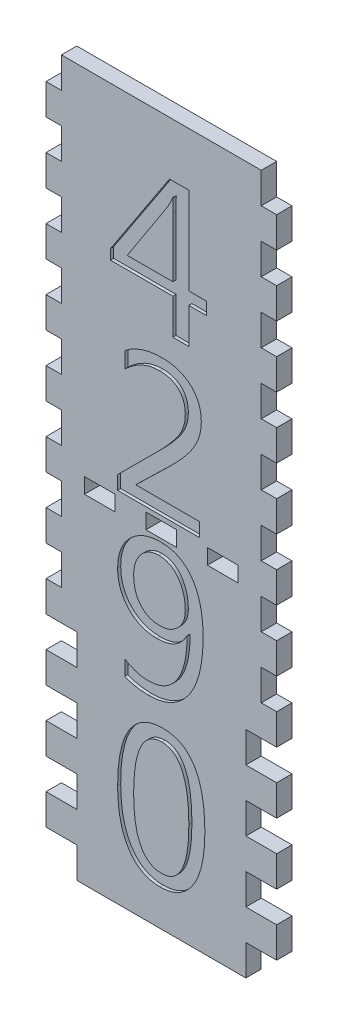
from build123d import *

# Parameters (mm, degrees)
SKETCH1_W           = 95.25
SKETCH1_H           = 292.1
BOSS_EXTRUDE1_DEPTH = 6.35
SKETCH2_W           = 6.35
SKETCH2_H           = 12.7
CUT_EXTRUDE1_DEPTH  = 7.35
LPATTERN1_COUNT     = 12
LPATTERN1_PITCH     = 25.4
SKETCH3_W           = 6.35
SKETCH3_H           = 12.7
CUT_EXTRUDE2_DEPTH  = 7.35
LPATTERN2_COUNT     = 4
LPATTERN2_PITCH     = 25.4
SKETCH4_W           = 12.7
SKETCH4_H           = 6.35
CUT_EXTRUDE3_DEPTH  = 7.35
LPATTERN3_COUNT     = 2
LPATTERN3_PITCH     = 25.4
LPATTERN3_COL_COUNT = 2
LPATTERN3_COL_PITCH = 25.4
CUT_EXTRUDE4_DEPTH  = 1.27


with BuildPart() as part:
    # Sketch1 → Boss-Extrude1 (new body)
    with BuildSketch(Plane.XY):
        with Locations((47.625, 146.05)):
            Rectangle(SKETCH1_W, SKETCH1_H)
    extrude(amount=BOSS_EXTRUDE1_DEPTH)

    # Sketch2 → Cut-Extrude1 (cut, through all)
    with BuildSketch(Plane.XY.offset(6.35)):
        with Locations((3.175, 6.35)):
            Rectangle(SKETCH2_W, SKETCH2_H)
        with Locations((92.075, 6.35)):
            Rectangle(SKETCH2_W, SKETCH2_H)
    cut_extrude1 = extrude(amount=-CUT_EXTRUDE1_DEPTH, mode=Mode.SUBTRACT)

    # LPattern1: Cut-Extrude1 ×12
    with Locations(*[(0, i * LPATTERN1_PITCH, 0) for i in range(1, LPATTERN1_COUNT)]):
        add(cut_extrude1, mode=Mode.SUBTRACT)

    # Sketch3 → Cut-Extrude2 (cut, through all)
    with BuildSketch(Plane.XY.offset(6.35)):
        with Locations((85.725, 6.35)):
            Rectangle(SKETCH3_W, SKETCH3_H)
        with Locations((9.525, 6.35)):
            Rectangle(SKETCH3_W, SKETCH3_H)
    cut_extrude2 = extrude(amount=-CUT_EXTRUDE2_DEPTH, mode=Mode.SUBTRACT)

    # LPattern2: Cut-Extrude2 ×4
    with Locations(*[(0, i * LPATTERN2_PITCH, 0) for i in range(1, LPATTERN2_COUNT)]):
        add(cut_extrude2, mode=Mode.SUBTRACT)

    # Sketch4 → Cut-Extrude3 (cut, through all)
    with BuildSketch(Plane.XY.offset(6.35)):
        with Locations((47.625, 142.875)):
            Rectangle(SKETCH4_W, SKETCH4_H)
    cut_extrude3 = extrude(amount=-CUT_EXTRUDE3_DEPTH, mode=Mode.SUBTRACT)

    # LPattern3: Cut-Extrude3 ×2
    with Locations(*[(-i * LPATTERN3_PITCH, 0, 0) for i in range(1, LPATTERN3_COUNT)]):
        add(cut_extrude3, mode=Mode.SUBTRACT)

    # LPattern3 col: Cut-Extrude3 ×2
    with Locations(*[(i * LPATTERN3_COL_PITCH, 0, 0) for i in range(1, LPATTERN3_COL_COUNT)]):
        add(cut_extrude3, mode=Mode.SUBTRACT)

    # Sketch5 → Cut-Extrude4 (cut)
    with BuildSketch(Plane.XY.offset(6.35)):
        Polygon((66.347473684, 228.827263158), (58.994842105, 228.827263158), (58.994842105, 214.122), (52.377473684, 214.122), (52.377473684, 228.827263158), (26.643263158, 228.827263158), (26.643263158, 232.963118421), (50.987366776, 270.002), (58.994842105, 270.002), (58.994842105, 233.974105263), (66.347473684, 233.974105263), align=None)
        with BuildLine():
            Line((52.377473684, 233.974105263), (52.377473684, 258.306720395))
            add(Edge.make_bspline(
                [(52.377473684, 258.306720395), (52.388280309, 259.222092385), (52.411121203, 261.156823508), (52.494422978, 263.089912378), (52.5383125, 264.10840625)],
                knots=[0, 0, 0, 0, 0.002746133, 0.005804229, 0.005804229, 0.005804229, 0.005804229], degree=3))
            Line((52.5383125, 264.10840625), (52.377473684, 264.10840625))
            add(Edge.make_bspline(
                [(52.377473684, 264.10840625), (52.268298001, 263.83954225), (52.024369803, 263.238826877), (51.566852144, 262.248813106), (50.970030559, 261.082008962), (50.525074381, 260.240044684), (50.286569079, 259.788735197)],
                knots=[0, 0, 0, 0, 0.000870476, 0.001944879, 0.003270444, 0.004801821, 0.004801821, 0.004801821, 0.004801821], degree=3))
            Line((50.286569079, 259.788735197), (33.54784375, 233.974105263))
            Line((33.54784375, 233.974105263), (52.377473684, 233.974105263))
        make_face(mode=Mode.SUBTRACT)
        with BuildLine():
            Line((63.406421053, 147.948315789), (29.584315789, 147.948315789))
            Line((29.584315789, 147.948315789), (29.584315789, 153.600651316))
            Line((29.584315789, 153.600651316), (45.920944079, 169.879837171))
            add(Edge.make_bspline(
                [(45.920944079, 169.879837171), (46.424180259, 170.383776596), (47.403956985, 171.364922505), (48.802074245, 172.816703689), (50.083014798, 174.213140989), (51.251077352, 175.545602605), (52.323826912, 176.800147905), (53.264671489, 178.002862364), (54.110599327, 179.125432912), (55.067027443, 180.531922001), (56.059985441, 182.284722154), (56.911097233, 184.479906643), (57.419517358, 186.752388241), (57.489331051, 188.29339001), (57.524315789, 189.065610197)],
                knots=[0, 0, 0, 0, 0.002136519, 0.0041597, 0.006046122, 0.007820712, 0.009475573, 0.010997092, 0.012400993, 0.013691493, 0.016098407, 0.018426066, 0.020731362, 0.023046969, 0.023046969, 0.023046969, 0.023046969], degree=3))
            add(Edge.make_bspline(
                [(57.524315789, 189.065610197), (57.514635558, 189.464149993), (57.495690632, 190.244121662), (57.37335109, 191.379250653), (57.151643335, 192.442992955), (56.856810686, 193.438501691), (56.464816334, 194.364107925), (55.978947694, 195.217158354), (55.413223909, 196.003273896), (54.768993183, 196.719412387), (54.039830798, 197.355755675), (53.231194025, 197.905309313), (52.353349238, 198.384423002), (51.393154072, 198.756728995), (50.368207585, 199.060082751), (49.266601956, 199.261146269), (48.095317636, 199.389752189), (47.288431348, 199.407587237), (46.874488487, 199.416736842)],
                knots=[0, 0, 0, 0, 0.001195686, 0.002340045, 0.003419291, 0.004451466, 0.005450106, 0.00642764, 0.007390551, 0.008350372, 0.009311156, 0.010286257, 0.011278333, 0.012304481, 0.013369694, 0.014480518, 0.015659138, 0.016900745, 0.016900745, 0.016900745, 0.016900745], degree=3))
            add(Edge.make_bspline(
                [(46.874488487, 199.416736842), (46.25286361, 199.39664315), (45.005788435, 199.35633211), (43.151945351, 199.034571391), (41.319800132, 198.512310756), (39.508805702, 197.780091001), (37.713595454, 196.849243103), (35.949789473, 195.694774033), (34.195710705, 194.353210173), (33.09149022, 193.326005205), (32.525368421, 192.799368421)],
                knots=[0, 0, 0, 0, 0.001864005, 0.00373948, 0.005626847, 0.007570338, 0.009589731, 0.011683348, 0.013887013, 0.016205439, 0.016205439, 0.016205439, 0.016205439], degree=3))
            Line((32.525368421, 192.799368421), (32.525368421, 199.474179276))
            add(Edge.make_bspline(
                [(32.525368421, 199.474179276), (33.081392691, 199.882781464), (34.185531177, 200.694173026), (35.952907748, 201.721204914), (37.777449228, 202.607833765), (39.677783191, 203.310952614), (41.639874019, 203.888883805), (43.677191261, 204.264705656), (45.776598564, 204.520351154), (47.199206981, 204.549042896), (47.919940789, 204.563578947)],
                knots=[0, 0, 0, 0, 0.002068725, 0.004108021, 0.006122277, 0.008147284, 0.010179837, 0.012250476, 0.014355253, 0.016516585, 0.016516585, 0.016516585, 0.016516585], degree=3))
            add(Edge.make_bspline(
                [(47.919940789, 204.563578947), (48.533340814, 204.555587419), (49.729010038, 204.540009943), (51.470941529, 204.330696975), (53.120401315, 204.035474499), (54.662404553, 203.578331525), (56.112970377, 203.023327851), (57.447087516, 202.313885893), (58.692614943, 201.49465137), (59.824127913, 200.544349453), (60.834571124, 199.483587928), (61.72598193, 198.344308658), (62.480063224, 197.116097248), (63.091123142, 195.797217168), (63.562169027, 194.390192145), (63.890647629, 192.8956227), (64.104976112, 191.319709362), (64.129277518, 190.238157461), (64.141684211, 189.685988487)],
                knots=[0, 0, 0, 0, 0.001839055, 0.003584776, 0.005256657, 0.00685999, 0.008402445, 0.009908139, 0.011383414, 0.012867609, 0.014330216, 0.015771094, 0.017199598, 0.018643907, 0.020122534, 0.021641536, 0.023228986, 0.024884763, 0.024884763, 0.024884763, 0.024884763], degree=3))
            add(Edge.make_bspline(
                [(64.141684211, 189.685988487), (64.132428295, 189.241483869), (64.113872596, 188.350367965), (63.976184445, 187.016687035), (63.726945853, 185.695411946), (63.410558875, 184.375553), (62.979788994, 183.069290717), (62.466493615, 181.764491649), (61.834268288, 180.480490523), (61.134460559, 179.174547227), (60.286394085, 177.850619886), (59.30784552, 176.460154214), (58.178086715, 174.990859647), (56.903533298, 173.441799938), (55.473594387, 171.81790248), (53.885244676, 170.126698203), (52.166776858, 168.340642787), (50.948525035, 167.149971807), (50.321034539, 166.5366875)],
                knots=[0, 0, 0, 0, 0.001333457, 0.002673233, 0.004016256, 0.005364869, 0.006741811, 0.008139163, 0.009567621, 0.011032797, 0.012581827, 0.014280648, 0.016132683, 0.018140573, 0.020297749, 0.022622515, 0.025100542, 0.027732634, 0.027732634, 0.027732634, 0.027732634], degree=3))
            Line((50.321034539, 166.5366875), (37.224159539, 153.830421053))
            Line((37.224159539, 153.830421053), (37.224159539, 153.681070724))
            Line((37.224159539, 153.681070724), (63.406421053, 153.681070724))
            Line((63.406421053, 153.681070724), (63.406421053, 147.948315789))
        make_face()
        with BuildLine():
            Line((32.525368421, 82.923480263), (32.525368421, 89.127263158))
            add(Edge.make_bspline(
                [(32.525368421, 89.127263158), (32.912936327, 88.89208708), (33.678389294, 88.427610471), (34.866453366, 87.832549391), (36.068817976, 87.318345854), (37.292372091, 86.911192909), (38.530987956, 86.583113547), (39.783313171, 86.356228425), (41.05410218, 86.21202138), (41.907246616, 86.194850605), (42.336536184, 86.186210526)],
                knots=[0, 0, 0, 0, 0.00135953, 0.002685095, 0.003982429, 0.005279408, 0.006550067, 0.007823218, 0.009094449, 0.01038198, 0.01038198, 0.01038198, 0.01038198], degree=3))
            add(Edge.make_bspline(
                [(42.336536184, 86.186210526), (42.946840108, 86.200946099), (44.144526951, 86.229863823), (45.882181555, 86.542613636), (47.524655753, 87.016924585), (49.048920459, 87.718651516), (50.476758173, 88.596819317), (51.79948828, 89.677064369), (53.003390312, 90.96406971), (54.110582692, 92.430014014), (55.094984841, 94.074709594), (55.950028018, 95.890915017), (56.648828462, 97.874485624), (57.255082891, 100.008860682), (57.708820054, 102.314565964), (58.021142036, 104.782934387), (58.221038608, 107.413666713), (58.246472616, 109.220248963), (58.259578947, 110.151194079)],
                knots=[0, 0, 0, 0, 0.00182898, 0.00358927, 0.005279483, 0.006945274, 0.008606344, 0.010296558, 0.01205193, 0.01388091, 0.015797973, 0.017791979, 0.019892456, 0.022100189, 0.02444339, 0.026934273, 0.029560919, 0.032353472, 0.032353472, 0.032353472, 0.032353472], degree=3))
            add(Edge.make_bspline(
                [(58.259578947, 110.151194079), (58.2327466, 110.145138734), (58.182832194, 110.133874385), (58.133186442, 110.145717455), (58.110228618, 110.151194079)],
                knots=[0, 0, 0, 0, 8.1236e-05, 0.000151118, 0.000151118, 0.000151118, 0.000151118], degree=3))
            add(Edge.make_bspline(
                [(58.110228618, 110.151194079), (57.804701544, 109.589492974), (57.206941762, 108.490532005), (56.053306012, 107.045275545), (54.741629714, 105.819729519), (53.260874947, 104.824266521), (51.624592639, 104.030493463), (49.814001076, 103.484788036), (47.843315767, 103.163468208), (46.477466043, 103.119820388), (45.77159375, 103.097263158)],
                knots=[0, 0, 0, 0, 0.001915238, 0.003747138, 0.005519272, 0.007281361, 0.009079777, 0.0109549, 0.012934257, 0.015051258, 0.015051258, 0.015051258, 0.015051258], degree=3))
            add(Edge.make_bspline(
                [(45.77159375, 103.097263158), (45.192405325, 103.107632938), (44.056016077, 103.127978834), (42.396333729, 103.372661183), (40.809670362, 103.728584475), (39.312631323, 104.267252894), (37.887576693, 104.931674648), (36.547392936, 105.758366028), (35.278357211, 106.721248715), (34.114581442, 107.840569835), (33.044898229, 109.058436135), (32.121934878, 110.39115868), (31.340217275, 111.80904629), (30.691575304, 113.307674722), (30.197631483, 114.895443032), (29.846027329, 116.564755584), (29.618227914, 118.320900922), (29.595785295, 119.521243224), (29.584315789, 120.134689145)],
                knots=[0, 0, 0, 0, 0.00173613, 0.003406353, 0.00502264, 0.006606885, 0.008169193, 0.009731669, 0.011321736, 0.01293884, 0.014567533, 0.016176946, 0.0177916, 0.019417779, 0.021067407, 0.022770883, 0.024530723, 0.026370173, 0.026370173, 0.026370173, 0.026370173], degree=3))
            add(Edge.make_bspline(
                [(29.584315789, 120.134689145), (29.600375888, 120.786335692), (29.631937134, 122.066949062), (29.861617632, 123.940800498), (30.253855131, 125.725737199), (30.803813016, 127.420992286), (31.521181877, 129.024041193), (32.388737239, 130.541756553), (33.411194923, 131.967828642), (34.587533996, 133.285513275), (35.870523495, 134.490619385), (37.274244162, 135.524883666), (38.750262088, 136.419432437), (40.320385368, 137.149436701), (41.985533271, 137.694277085), (43.729880254, 138.100337261), (45.565477077, 138.345900474), (46.820120703, 138.375029407), (47.460401316, 138.389894737)],
                knots=[0, 0, 0, 0, 0.001954698, 0.003841365, 0.005653198, 0.007429758, 0.009178312, 0.010912502, 0.012666031, 0.01443201, 0.016204144, 0.017936621, 0.019652718, 0.02137465, 0.02311848, 0.024899233, 0.026741765, 0.028662027, 0.028662027, 0.028662027, 0.028662027], degree=3))
            add(Edge.make_bspline(
                [(47.460401316, 138.389894737), (48.127912342, 138.370173716), (49.431578674, 138.331658052), (51.332659893, 138.02629614), (53.122665565, 137.527701518), (54.792779881, 136.801345934), (56.356982153, 135.896122164), (57.793392304, 134.761736953), (59.117633164, 133.43359825), (60.327238032, 131.907528756), (61.409192721, 130.191486011), (62.33628842, 128.280686722), (63.131217748, 126.194066789), (63.768214418, 123.916059832), (64.272112041, 121.45920303), (64.619370885, 118.813861634), (64.843521788, 115.991236889), (64.865597758, 114.046244547), (64.876947368, 113.046292763)],
                knots=[0, 0, 0, 0, 0.002001669, 0.003909311, 0.005760384, 0.00756155, 0.009358535, 0.011167196, 0.013035621, 0.014973365, 0.016997329, 0.019109024, 0.021334412, 0.023687309, 0.026197274, 0.028852134, 0.031686719, 0.034686006, 0.034686006, 0.034686006, 0.034686006], degree=3))
            add(Edge.make_bspline(
                [(64.876947368, 113.046292763), (64.861802976, 111.801049441), (64.832356379, 109.379811463), (64.533481599, 105.863288844), (64.088211472, 102.564336071), (63.43558059, 99.482911486), (62.585662748, 96.622785211), (61.572939263, 93.972484241), (60.34373022, 91.556506151), (58.949486364, 89.354769775), (57.374279726, 87.399591852), (55.655046202, 85.6897636), (53.776052141, 84.253670751), (51.75544253, 83.072424633), (49.583434361, 82.159419668), (47.26974228, 81.504277135), (44.805101643, 81.104873378), (43.111621088, 81.061548822), (42.244628289, 81.039368421)],
                knots=[0, 0, 0, 0, 0.003734889, 0.007262079, 0.010579766, 0.013716313, 0.016700601, 0.01952317, 0.022215425, 0.024819159, 0.027327466, 0.029732103, 0.032075867, 0.034402931, 0.036735122, 0.039124313, 0.04160234, 0.044201812, 0.044201812, 0.044201812, 0.044201812], degree=3))
            add(Edge.make_bspline(
                [(42.244628289, 81.039368421), (41.343255123, 81.058701793), (39.590477559, 81.096296768), (37.059435016, 81.464629547), (34.69454084, 82.028078778), (33.238981842, 82.628911463), (32.525368421, 82.923480263)],
                knots=[0, 0, 0, 0, 0.002702238, 0.005254673, 0.00765931, 0.009972122, 0.009972122, 0.009972122, 0.009972122], degree=3))
        make_face()
        with BuildLine():
            add(Edge.make_bspline(
                [(46.679184211, 133.243052632), (46.310968442, 133.23158205), (45.59008635, 133.209125279), (44.529792041, 133.044728), (43.52066024, 132.769682214), (42.552665786, 132.385649856), (41.635200172, 131.89214852), (40.762959658, 131.284154237), (39.938018377, 130.573202533), (39.168297814, 129.756648762), (38.479174117, 128.85560251), (37.856190022, 127.898643248), (37.359411967, 126.865831312), (36.924369382, 125.787637076), (36.612051257, 124.640357299), (36.36239475, 123.441062363), (36.228523506, 122.178862629), (36.210720889, 121.31827728), (36.201684211, 120.881440789)],
                knots=[0, 0, 0, 0, 0.00110439, 0.002162142, 0.003210053, 0.004236201, 0.005279631, 0.006328109, 0.007419697, 0.008541222, 0.009687886, 0.010819254, 0.011959859, 0.013120424, 0.014302399, 0.015521316, 0.016792547, 0.01810304, 0.01810304, 0.01810304, 0.01810304], degree=3))
            add(Edge.make_bspline(
                [(36.201684211, 120.881440789), (36.20999761, 120.402399367), (36.226195299, 119.469043034), (36.366586465, 118.109574578), (36.592845366, 116.82950628), (36.916801579, 115.626726646), (37.324431864, 114.500341718), (37.837663118, 113.45582357), (38.43359303, 112.486596172), (39.124351527, 111.601651295), (39.889072997, 110.809433923), (40.729577816, 110.125529575), (41.624448454, 109.531866838), (42.597723306, 109.064000413), (43.629043223, 108.692668897), (44.726144865, 108.426528708), (45.890279725, 108.281943045), (46.686471439, 108.256889923), (47.092769737, 108.244105263)],
                knots=[0, 0, 0, 0, 0.001436796, 0.002799429, 0.004095186, 0.005332534, 0.006531967, 0.007682882, 0.008817861, 0.009939328, 0.011044255, 0.012113672, 0.013184323, 0.014258173, 0.015344732, 0.016467669, 0.017637578, 0.018856712, 0.018856712, 0.018856712, 0.018856712], degree=3))
            add(Edge.make_bspline(
                [(47.092769737, 108.244105263), (47.449480176, 108.251704011), (48.154654706, 108.266725842), (49.189217154, 108.423013863), (50.182133648, 108.662624162), (51.134949596, 108.997418778), (52.041943028, 109.436342447), (52.908055464, 109.96728362), (53.731246072, 110.594967521), (54.503444708, 111.311686543), (55.207093538, 112.098870326), (55.841060671, 112.927760084), (56.352246769, 113.817389653), (56.781161725, 114.739413346), (57.118869083, 115.704597037), (57.358966736, 116.712740176), (57.498612114, 117.767953222), (57.51564773, 118.483761262), (57.524315789, 118.847978618)],
                knots=[0, 0, 0, 0, 0.001069417, 0.002114112, 0.003131151, 0.004130385, 0.005137513, 0.006148304, 0.007173101, 0.008238065, 0.009303773, 0.010337737, 0.01136234, 0.012374958, 0.01338503, 0.014424405, 0.015478908, 0.016571281, 0.016571281, 0.016571281, 0.016571281], degree=3))
            add(Edge.make_bspline(
                [(57.524315789, 118.847978618), (57.515590114, 119.365236242), (57.498494246, 120.378678433), (57.361620172, 121.865337031), (57.120044386, 123.277923754), (56.789439515, 124.615715491), (56.359355973, 125.878679381), (55.846114029, 127.072359697), (55.237843783, 128.19661383), (54.521968803, 129.223369477), (53.750181552, 130.165490831), (52.908231716, 130.989307053), (52.004311939, 131.678058381), (51.059004995, 132.268809235), (50.040596132, 132.700933537), (48.968354698, 133.011937265), (47.843526257, 133.217097066), (47.070696096, 133.234325031), (46.679184211, 133.243052632)],
                knots=[0, 0, 0, 0, 0.001551626, 0.00304004, 0.004473571, 0.00584725, 0.007169674, 0.008471528, 0.009741408, 0.010996969, 0.012220803, 0.013390713, 0.014521264, 0.015624637, 0.016725855, 0.017827373, 0.018970059, 0.020143291, 0.020143291, 0.020143291, 0.020143291], degree=3))
        make_face(mode=Mode.SUBTRACT)
        with BuildLine():
            add(Edge.make_bspline(
                [(47.023838816, 14.865684211), (46.356005098, 14.887332682), (45.050006657, 14.929667875), (43.147679081, 15.274062109), (41.35725295, 15.820259372), (39.679017461, 16.601072431), (38.120255616, 17.609308627), (36.674354213, 18.839316475), (35.347935423, 20.289351278), (34.139052712, 21.954244276), (33.061403958, 23.829667006), (32.134104782, 25.911648241), (31.343907394, 28.183908116), (30.690601367, 30.649056472), (30.187683718, 33.313887474), (29.843507875, 36.173390094), (29.616912136, 39.229112264), (29.595408307, 41.33089415), (29.584315789, 42.415075658)],
                knots=[0, 0, 0, 0, 0.002002295, 0.003915637, 0.005779784, 0.007604429, 0.009449538, 0.011332424, 0.013283776, 0.01533121, 0.017492909, 0.019760569, 0.02215861, 0.024702862, 0.027404416, 0.030287133, 0.033339398, 0.03659137, 0.03659137, 0.03659137, 0.03659137], degree=3))
            add(Edge.make_bspline(
                [(29.584315789, 42.415075658), (29.601056036, 43.602522971), (29.633539962, 45.906727315), (29.846065696, 49.251405128), (30.222202445, 52.373904029), (30.750704962, 55.273554868), (31.403583291, 57.959320671), (32.230926575, 60.415182968), (33.206542895, 62.648185296), (34.33191519, 64.655186967), (35.594533673, 66.438972578), (37.006993601, 67.983412781), (38.556378032, 69.291340774), (40.233300859, 70.371234413), (42.049294966, 71.211850883), (44.004736075, 71.787469777), (46.086918994, 72.157989545), (47.520042049, 72.196507824), (48.253106908, 72.216210526)],
                knots=[0, 0, 0, 0, 0.003562339, 0.006912607, 0.010048985, 0.012991922, 0.015750427, 0.018333497, 0.020756288, 0.023050537, 0.025224746, 0.027298187, 0.029311952, 0.031290975, 0.033264856, 0.035292892, 0.037391263, 0.039588569, 0.039588569, 0.039588569, 0.039588569], degree=3))
            add(Edge.make_bspline(
                [(48.253106908, 72.216210526), (48.955387579, 72.194867971), (50.322276199, 72.153327748), (52.304514945, 71.809450822), (54.156677021, 71.268621383), (55.865100095, 70.472131439), (57.440448645, 69.467298666), (58.880244593, 68.235197164), (60.170947171, 66.772697136), (61.321314642, 65.089308706), (62.34714995, 63.192442907), (63.229920094, 61.071194318), (63.952814924, 58.719895665), (64.578409216, 56.159707186), (65.039309241, 53.370828769), (65.364130166, 50.367465298), (65.577005405, 47.143716115), (65.600215894, 44.919921606), (65.612210526, 43.770717105)],
                knots=[0, 0, 0, 0, 0.00210553, 0.004098112, 0.006017205, 0.00787795, 0.009732727, 0.011606865, 0.01354362, 0.015567193, 0.017710866, 0.02000238, 0.022447701, 0.025083676, 0.027903509, 0.030920457, 0.034143873, 0.037591108, 0.037591108, 0.037591108, 0.037591108], degree=3))
            add(Edge.make_bspline(
                [(65.612210526, 43.770717105), (65.596857991, 42.632937292), (65.566998836, 40.42006879), (65.334385396, 37.206582472), (64.965398586, 34.197165692), (64.425476312, 31.399521183), (63.743050989, 28.809093471), (62.904541937, 26.423589079), (61.909462377, 24.247652373), (60.759203184, 22.283412354), (59.471452448, 20.543301928), (58.064478217, 19.019821771), (56.524774627, 17.732687084), (54.862005296, 16.67652601), (53.068125753, 15.868595768), (51.163745518, 15.278628561), (49.131452571, 14.928092986), (47.737507984, 14.886816744), (47.023838816, 14.865684211)],
                knots=[0, 0, 0, 0, 0.003413028, 0.006638, 0.009660367, 0.012503809, 0.015179048, 0.01768988, 0.020080203, 0.022346087, 0.024505953, 0.026562521, 0.028552717, 0.030509709, 0.032453132, 0.034437217, 0.03647703, 0.038616975, 0.038616975, 0.038616975, 0.038616975], degree=3))
        make_face()
        with BuildLine():
            add(Edge.make_bspline(
                [(47.908452303, 67.069368421), (47.435879533, 67.053421335), (46.508356758, 67.022121848), (45.16782451, 66.725839038), (43.915086197, 66.249832932), (42.754712428, 65.579544114), (41.701732615, 64.697064131), (40.732122623, 63.643479086), (39.852459374, 62.402455997), (39.088839331, 60.95962456), (38.402397496, 59.337335836), (37.803263829, 57.524806733), (37.322633396, 55.519830206), (36.906082667, 53.331470865), (36.590119901, 50.949440551), (36.365017661, 48.377345153), (36.225910538, 45.618068827), (36.209928506, 43.717273983), (36.201684211, 42.736753289)],
                knots=[0, 0, 0, 0, 0.00141607, 0.002779332, 0.004095755, 0.005423855, 0.00677862, 0.008201385, 0.00970918, 0.011328405, 0.013088845, 0.014988896, 0.017048029, 0.019269678, 0.021669452, 0.02425311, 0.027013791, 0.029955203, 0.029955203, 0.029955203, 0.029955203], degree=3))
            add(Edge.make_bspline(
                [(36.201684211, 42.736753289), (36.209608411, 41.817473089), (36.224938109, 40.039087049), (36.367514665, 37.464061462), (36.58007432, 35.067959751), (36.880962624, 32.845062941), (37.301674888, 30.804406286), (37.771323598, 28.928870938), (38.355255132, 27.237220088), (39.034835364, 25.723655162), (39.790575697, 24.377901063), (40.640372103, 23.2072291), (41.587797044, 22.216037629), (42.633811412, 21.416773635), (43.76479383, 20.782012559), (44.990156547, 20.33526583), (46.307435812, 20.064421806), (47.214003823, 20.030112305), (47.678682566, 20.012526316)],
                knots=[0, 0, 0, 0, 0.00275762, 0.005334731, 0.007734285, 0.009973155, 0.01205951, 0.013982176, 0.015769734, 0.017420322, 0.018953594, 0.020392043, 0.021748901, 0.023051768, 0.024327197, 0.025624786, 0.026949603, 0.028342745, 0.028342745, 0.028342745, 0.028342745], degree=3))
            add(Edge.make_bspline(
                [(47.678682566, 20.012526316), (48.135541313, 20.03075103), (49.030369127, 20.066446923), (50.332491337, 20.330143226), (51.538427441, 20.79814204), (52.65425963, 21.436836971), (53.682660764, 22.256058558), (54.611094734, 23.264752822), (55.45280668, 24.453066634), (56.214546884, 25.813480913), (56.858543834, 27.365167632), (57.432478135, 29.085395135), (57.928542138, 30.983656973), (58.30657627, 33.066923064), (58.615421524, 35.324709052), (58.847616814, 37.761875719), (58.966346983, 40.384239315), (58.985134657, 42.192860826), (58.994842105, 43.127361842)],
                knots=[0, 0, 0, 0, 0.001370216, 0.002683777, 0.003963906, 0.005234982, 0.006526811, 0.007892443, 0.009333459, 0.010886743, 0.012559689, 0.014365283, 0.016324196, 0.018439982, 0.02071299, 0.023159363, 0.025781785, 0.028585352, 0.028585352, 0.028585352, 0.028585352], degree=3))
            add(Edge.make_bspline(
                [(58.994842105, 43.127361842), (58.98540012, 44.092513565), (58.967107155, 45.96240487), (58.844451132, 48.675975703), (58.625261939, 51.204964087), (58.33501125, 53.548854499), (57.947360195, 55.705333811), (57.465906709, 57.673251651), (56.90909079, 59.4569522), (56.268664485, 61.056193276), (55.534474597, 62.468245892), (54.709899897, 63.694560273), (53.790859557, 64.734735904), (52.790493851, 65.593624676), (51.694862461, 66.265581379), (50.504909928, 66.718412589), (49.237352819, 67.024717279), (48.358379916, 67.054250824), (47.908452303, 67.069368421)],
                knots=[0, 0, 0, 0, 0.002895463, 0.00560969, 0.008146565, 0.010509175, 0.012692743, 0.014715663, 0.01658324, 0.018294215, 0.01987696, 0.021349101, 0.022716279, 0.024028433, 0.025291383, 0.026550093, 0.027834854, 0.029182145, 0.029182145, 0.029182145, 0.029182145], degree=3))
        make_face(mode=Mode.SUBTRACT)
    extrude(amount=-CUT_EXTRUDE4_DEPTH, mode=Mode.SUBTRACT)


solid = part.part
